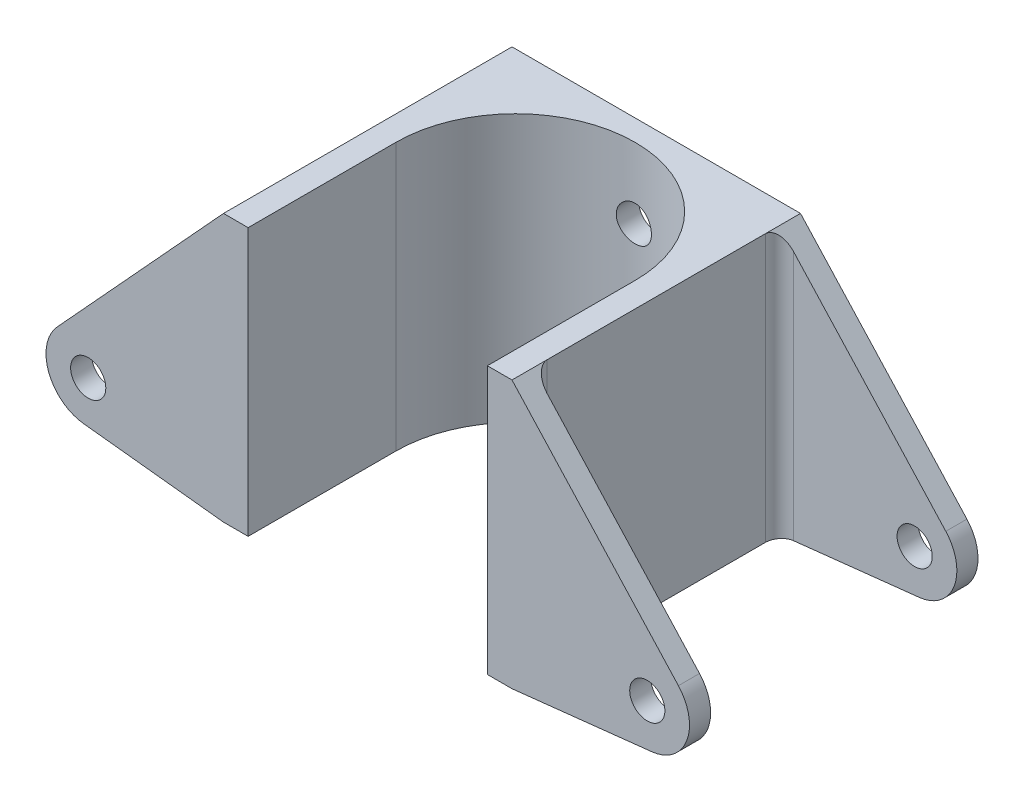
from build123d import *

# Parameters (mm, degrees)
BOSS_EXTRUDE1_DEPTH     = 41
SKETCH3_W               = 25.226628976
SKETCH3_H               = 35
CUT_EXTRUDE2_DEPTH      = 39
CUT_EXTRUDE2_DEPTH_BACK = 1
CUT_EXTRUDE3_DEPTH      = 39
SKETCH5_R               = 2.5
CUT_EXTRUDE4_DEPTH      = 42
SKETCH6_R               = 2.5
CUT_EXTRUDE5_DEPTH      = 42.0000001
FILLET1_R               = 2


with BuildPart() as part:
    # Sketch1 → Boss-Extrude1 (new body)
    with BuildSketch(Plane.XY):
        with BuildLine():
            Line((-20.5, 0), (-40.380779843, 2.180502889))
            ThreePointArc((-40.380779843, 2.180502889), (-45.342396797, 6.03211956), (-44.149663567, 12.198964882))
            Line((-44.149663567, 12.198964882), (-20.5, 38))
            Line((-20.5, 38), (20.5, 38))
            Line((20.5, 38), (44.149663567, 12.198964882))
            ThreePointArc((44.149663567, 12.198964882), (45.342396797, 6.03211956), (40.380779843, 2.180502889))
            Line((40.380779843, 2.180502889), (20.5, 0))
            Line((20.5, 0), (-20.5, 0))
        make_face()
    extrude(amount=BOSS_EXTRUDE1_DEPTH)

    # Sketch3 → Cut-Extrude2 (cut, two sides)
    with BuildSketch(Plane(origin=(0, 0, 0), x_dir=(1, 0, 0), z_dir=(0, 1, 0))) as cut_extrude2_sk:
        with Locations((33.113314488, -20.5)):
            Rectangle(SKETCH3_W, SKETCH3_H)
        with Locations((-33.113314488, -20.5)):
            Rectangle(SKETCH3_W, SKETCH3_H)
    extrude(amount=CUT_EXTRUDE2_DEPTH, mode=Mode.SUBTRACT)
    extrude(cut_extrude2_sk.sketch, amount=-CUT_EXTRUDE2_DEPTH_BACK, mode=Mode.SUBTRACT)

    # Sketch4 → Cut-Extrude3 (cut, through all)
    with BuildSketch(Plane.XZ):
        with BuildLine():
            Line((-17, 20), (-17, 41))
            Line((-17, 41), (17, 41))
            Line((17, 41), (17, 20))
            ThreePointArc((17, 20), (0, 3), (-17, 20))
        make_face()
    extrude(amount=-CUT_EXTRUDE3_DEPTH, mode=Mode.SUBTRACT)

    # Sketch5 → Cut-Extrude4 (cut, through all)
    with BuildSketch(Plane(origin=(0, 0, 0), x_dir=(-1, 0, 0), z_dir=(0, 0, -1))):
        with Locations((0, 28)):
            Circle(SKETCH5_R)
        with Locations((0, 10)):
            Circle(SKETCH5_R)
    extrude(amount=-CUT_EXTRUDE4_DEPTH, mode=Mode.SUBTRACT)

    # Sketch6 → Cut-Extrude5 (cut, through all)
    with BuildSketch(Plane.XY.offset(41)):
        with Locations((-39.726628976, 8.144736842)):
            Circle(SKETCH6_R)
    cut_extrude5 = extrude(amount=-CUT_EXTRUDE5_DEPTH, mode=Mode.SUBTRACT)

    # Mirror1: Cut-Extrude5 across plane
    add(cut_extrude5.mirror(Plane(origin=(0, 0, 0), x_dir=(0, 0, 1), z_dir=(1, 0, 0))), mode=Mode.SUBTRACT)

    # Fillet1
    fillet1_edges = [part.edges().sort_by_distance(p)[0] for p in [
        (20.5, 19, 3),
        (20.5, 19, 38),
        (-20.5, 19, 38),
        (-20.5, 19, 3),
    ]]
    fillet(fillet1_edges, radius=FILLET1_R)


solid = part.part
